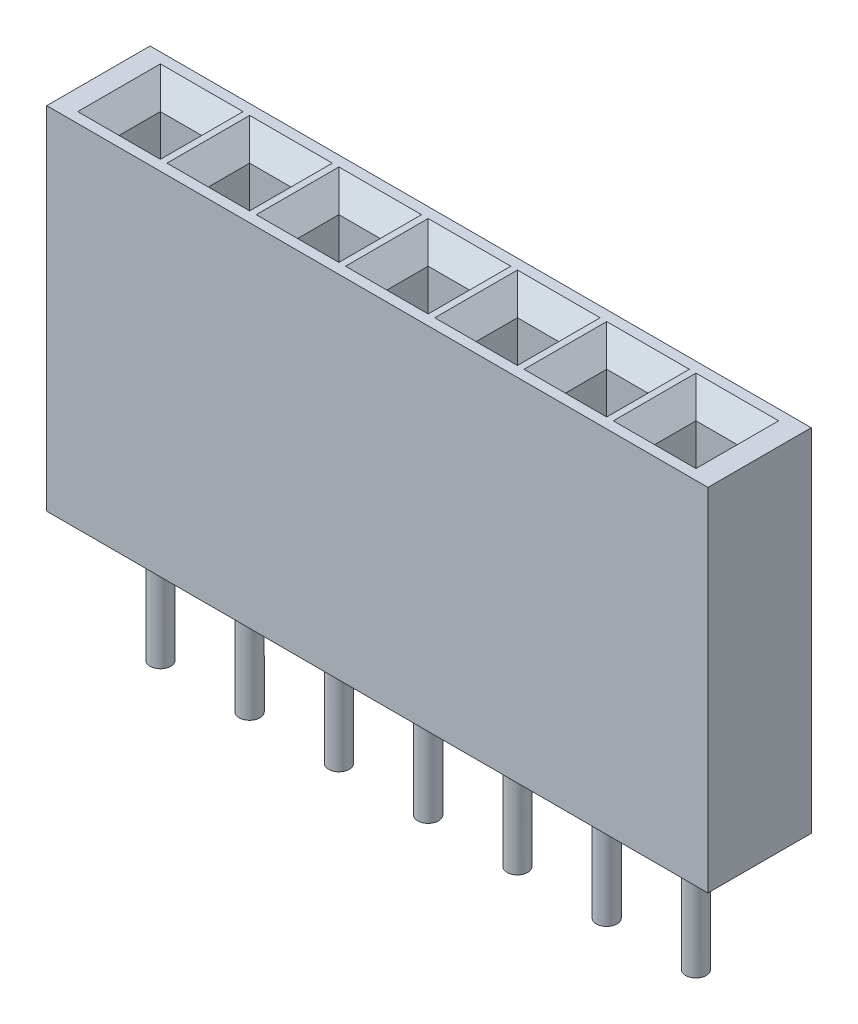
from build123d import *

# Parameters (mm, degrees)
SKETCH1_W           = 16
SKETCH1_H           = 2.5
BOSS_EXTRUDE1_DEPTH = 8.5
SKETCH2_W           = 1
SKETCH2_H           = 1
CUT_EXTRUDE1_DEPTH  = 5
CHAMFER1_SIZE       = 0.5
SKETCH3_R           = 0.25
BOSS_EXTRUDE2_DEPTH = 6.5


with BuildPart() as part:
    # Sketch1 → Boss-Extrude1 (new body)
    with BuildSketch(Plane(origin=(0, 0, 0), x_dir=(1, 0, 0), z_dir=(0, 1, 0))):
        with Locations((8, 1.25)):
            Rectangle(SKETCH1_W, SKETCH1_H)
    extrude(amount=BOSS_EXTRUDE1_DEPTH)

    # Sketch2 → Cut-Extrude1 (cut)
    with BuildSketch(Plane(origin=(0, 8.5, 0), x_dir=(1, 0, 0), z_dir=(0, 1, 0))):
        with Locations((1.5, 1.25)):
            Rectangle(SKETCH2_W, SKETCH2_H)
        with Locations((3.66, 1.25)):
            Rectangle(SKETCH2_W, SKETCH2_H)
        with Locations((5.82, 1.25)):
            Rectangle(SKETCH2_W, SKETCH2_H)
        with Locations((7.98, 1.25)):
            Rectangle(SKETCH2_W, SKETCH2_H)
        with Locations((10.14, 1.25)):
            Rectangle(SKETCH2_W, SKETCH2_H)
        with Locations((12.3, 1.25)):
            Rectangle(SKETCH2_W, SKETCH2_H)
        with Locations((14.46, 1.25)):
            Rectangle(SKETCH2_W, SKETCH2_H)
    extrude(amount=-CUT_EXTRUDE1_DEPTH, mode=Mode.SUBTRACT)

    # Chamfer1
    chamfer1_edges = [part.edges().sort_by_distance(p)[0] for p in [
        (1, 8.5, -1.25),
        (1.5, 8.5, -0.75),
        (2, 8.5, -1.25),
        (1.5, 8.5, -1.75),
        (3.16, 8.5, -1.25),
        (3.66, 8.5, -0.75),
        (4.16, 8.5, -1.25),
        (3.66, 8.5, -1.75),
        (5.32, 8.5, -1.25),
        (5.82, 8.5, -0.75),
        (6.32, 8.5, -1.25),
        (5.82, 8.5, -1.75),
        (7.48, 8.5, -1.25),
        (7.98, 8.5, -0.75),
        (8.48, 8.5, -1.25),
        (7.98, 8.5, -1.75),
        (9.64, 8.5, -1.25),
        (10.14, 8.5, -0.75),
        (10.64, 8.5, -1.25),
        (10.14, 8.5, -1.75),
        (11.8, 8.5, -1.25),
        (12.3, 8.5, -0.75),
        (12.8, 8.5, -1.25),
        (12.3, 8.5, -1.75),
        (13.96, 8.5, -1.25),
        (14.46, 8.5, -0.75),
        (14.96, 8.5, -1.25),
        (14.46, 8.5, -1.75),
    ]]
    chamfer(chamfer1_edges, length=CHAMFER1_SIZE)

    # Sketch3 → Boss-Extrude2 (add)
    with BuildSketch(Plane(origin=(0, 3.5, 0), x_dir=(1, 0, 0), z_dir=(0, 1, 0))):
        with Locations((1.5, 1.25)):
            Circle(SKETCH3_R)
        with Locations((3.66, 1.25)):
            Circle(SKETCH3_R)
        with Locations((5.82, 1.25)):
            Circle(SKETCH3_R)
        with Locations((7.98, 1.25)):
            Circle(SKETCH3_R)
        with Locations((10.14, 1.25)):
            Circle(SKETCH3_R)
        with Locations((12.3, 1.25)):
            Circle(SKETCH3_R)
        with Locations((14.46, 1.25)):
            Circle(SKETCH3_R)
    extrude(amount=-BOSS_EXTRUDE2_DEPTH)


solid = part.part
